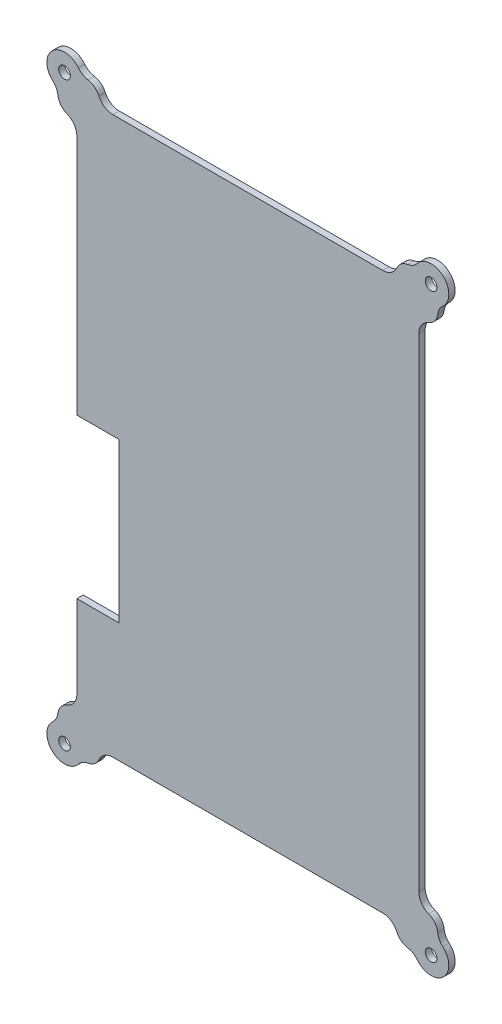
from build123d import *

# Parameters (mm, degrees)
SKETCH2_R           = 2.75
BOSS_EXTRUDE2_DEPTH = 3


with BuildPart() as part:
    # Sketch2 → Boss-Extrude2 (new body)
    with BuildSketch(Plane.XY):
        with BuildLine():
            Line((27.74070529, 245.594851313), (27.74070529, 131.5))
            Line((27.74070529, 131.5), (47.74070529, 131.5))
            Line((47.74070529, 131.5), (47.74070529, 56.5))
            Line((47.74070529, 56.5), (27.74070529, 56.5))
            Line((27.74070529, 56.5), (27.74070529, 17.405148687))
            ThreePointArc((27.74070529, 17.405148687), (26.47762478, 13.3410126), (23.133396465, 10.708768028))
            ThreePointArc((23.133396465, 10.708768028), (20.1856831, 8.526218264), (18.792007247, 5.133548935))
            ThreePointArc((18.792007247, 5.133548935), (18.020142632, 2.644369817), (16.409580407, 0.595497692))
            ThreePointArc((16.409580407, 0.595497692), (16.190613984, -11.709412188), (28.464054129, -10.803089717))
            ThreePointArc((28.464054129, -10.803089717), (30.468885152, -9.051370379), (32.974636764, -8.151883342))
            ThreePointArc((32.974636764, -8.151883342), (36.082059553, -6.807278123), (38.161890453, -4.135510355))
            ThreePointArc((38.161890453, -4.135510355), (40.806062267, -1.002196621), (44.734834928, 0.17))
            Line((44.734834928, 0.17), (172.134078399, 0.17))
            ThreePointArc((172.134078399, 0.17), (176.06285106, -1.002196621), (178.707022874, -4.135510355))
            ThreePointArc((178.707022874, -4.135510355), (180.786853774, -6.807278123), (183.894276563, -8.151883342))
            ThreePointArc((183.894276563, -8.151883342), (186.400028175, -9.051370379), (188.404859198, -10.803089717))
            ThreePointArc((188.404859198, -10.803089717), (200.678299343, -11.709412188), (200.45933292, 0.595497692))
            ThreePointArc((200.45933292, 0.595497692), (198.848770695, 2.644369817), (198.076906079, 5.133548935))
            ThreePointArc((198.076906079, 5.133548935), (196.683230227, 8.526218264), (193.735516862, 10.708768028))
            ThreePointArc((193.735516862, 10.708768028), (190.391288547, 13.3410126), (189.128208037, 17.405148687))
            Line((189.128208037, 17.405148687), (189.128208037, 245.594851313))
            ThreePointArc((189.128208037, 245.594851313), (190.391288547, 249.6589874), (193.735516862, 252.291231972))
            ThreePointArc((193.735516862, 252.291231972), (196.683230227, 254.473781736), (198.076906079, 257.866451065))
            ThreePointArc((198.076906079, 257.866451065), (198.848770695, 260.355630183), (200.45933292, 262.404502308))
            ThreePointArc((200.45933292, 262.404502308), (200.678299343, 274.709412188), (188.404859198, 273.803089717))
            ThreePointArc((188.404859198, 273.803089717), (186.400028175, 272.051370379), (183.894276563, 271.151883342))
            ThreePointArc((183.894276563, 271.151883342), (180.786853774, 269.807278123), (178.707022874, 267.135510355))
            ThreePointArc((178.707022874, 267.135510355), (176.06285106, 264.002196621), (172.134078399, 262.83))
            Line((172.134078399, 262.83), (44.734834928, 262.83))
            ThreePointArc((44.734834928, 262.83), (40.806062267, 264.002196621), (38.161890453, 267.135510355))
            ThreePointArc((38.161890453, 267.135510355), (36.082059553, 269.807278123), (32.974636764, 271.151883342))
            ThreePointArc((32.974636764, 271.151883342), (30.468885152, 272.051370379), (28.464054129, 273.803089717))
            ThreePointArc((28.464054129, 273.803089717), (16.190613984, 274.709412188), (16.409580407, 262.404502308))
            ThreePointArc((16.409580407, 262.404502308), (18.020142632, 260.355630183), (18.792007247, 257.866451065))
            ThreePointArc((18.792007247, 257.866451065), (20.1856831, 254.473781736), (23.133396465, 252.291231972))
            ThreePointArc((23.133396465, 252.291231972), (26.47762478, 249.6589874), (27.74070529, 245.594851313))
        make_face()
        with Locations((21.91385104, -5.656854249)):
            Circle(SKETCH2_R, mode=Mode.SUBTRACT)
        with Locations((194.955062287, -5.656854249)):
            Circle(SKETCH2_R, mode=Mode.SUBTRACT)
        with Locations((21.91385104, 268.656854249)):
            Circle(SKETCH2_R, mode=Mode.SUBTRACT)
        with Locations((194.955062287, 268.656854249)):
            Circle(SKETCH2_R, mode=Mode.SUBTRACT)
    extrude(amount=BOSS_EXTRUDE2_DEPTH)


solid = part.part
